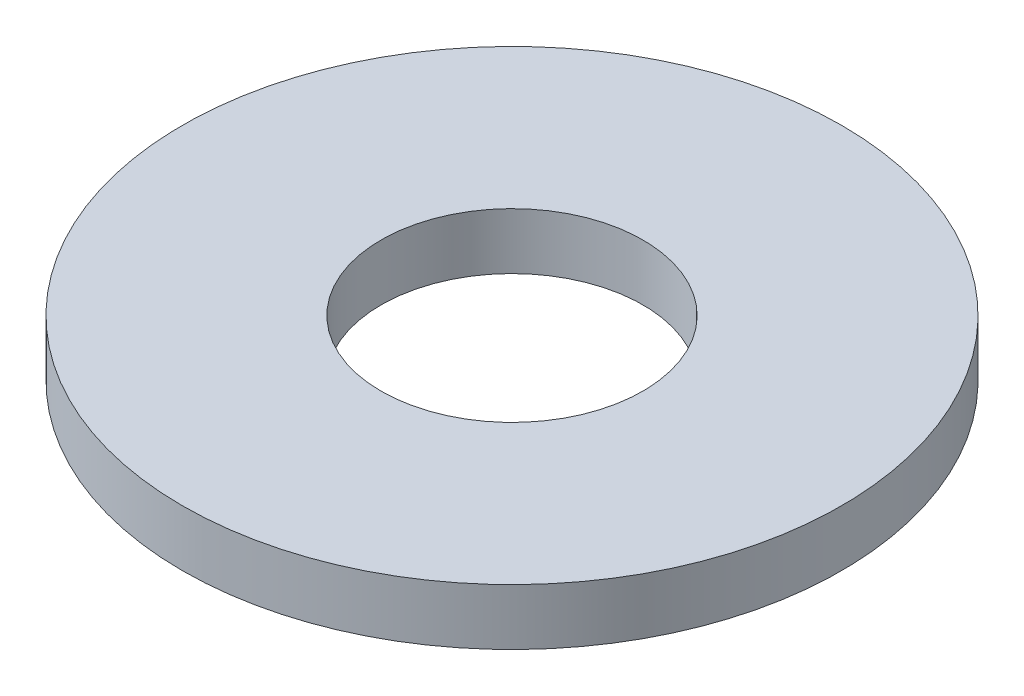
from build123d import *

# Parameters (mm, degrees)
SKETCH1_R           = 4.7625
SKETCH1_R_2         = 1.8923
BOSS_EXTRUDE1_DEPTH = 0.8128


with BuildPart() as part:
    # Sketch1 → Boss-Extrude1 (new body)
    with BuildSketch(Plane(origin=(0, 0, 0), x_dir=(1, 0, 0), z_dir=(0, 1, 0))):
        with Locations(Location((0, 0, 0), (0, 0, 270))):  # turned: the seam where the file's is
            Circle(SKETCH1_R)
        with Locations(Location((0, 0, 0), (0, 0, 270))):  # turned: the seam where the file's is
            Circle(SKETCH1_R_2, mode=Mode.SUBTRACT)
    extrude(amount=BOSS_EXTRUDE1_DEPTH)


solid = part.part
